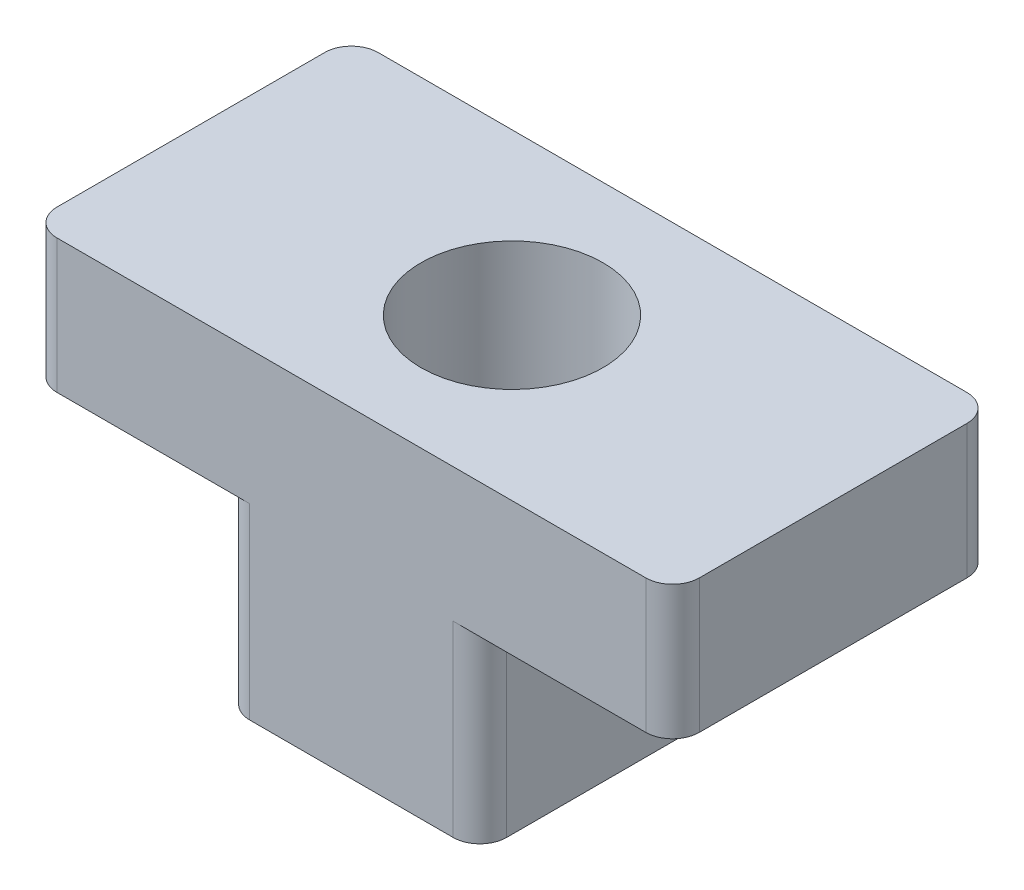
from build123d import *

# Parameters (mm, degrees)
BOSS_EXTRU_1_DEPTH      = 3
ESQUISSE2_R             = 1.7
ENL_V_MAT_EXTRU_1_DEPTH = 7
CONG_2_R                = 0.5


with BuildPart() as part:
    # Esquisse1 → Boss.-Extru.1 (new body, symmetric)
    with BuildSketch(Plane.XY):
        Polygon((-6, 0), (-2.4, 0), (-2.4, -3.5), (2.4, -3.5), (2.4, 0), (6, 0), (6, 2.5), (-6, 2.5), align=None)
    extrude(amount=BOSS_EXTRU_1_DEPTH, both=True)

    # Esquisse2 → Enlèv. mat.-Extru.1 (cut, through all)
    with BuildSketch(Plane(origin=(0, 2.5, 0), x_dir=(1, 0, 0), z_dir=(0, 1, 0))):
        Circle(ESQUISSE2_R)
    extrude(amount=-ENL_V_MAT_EXTRU_1_DEPTH, mode=Mode.SUBTRACT)

    # Congé2
    cong_2_edges = [part.edges().sort_by_distance(p)[0] for p in [
        (-6, 1.25, -3),
        (6, 1.25, -3),
        (-6, 1.25, 3),
        (-2.4, -1.75, 3),
        (2.4, -1.75, 3),
        (6, 1.25, 3),
        (2.4, -1.75, -3),
        (-2.4, -1.75, -3),
    ]]
    fillet(cong_2_edges, radius=CONG_2_R)


solid = part.part
